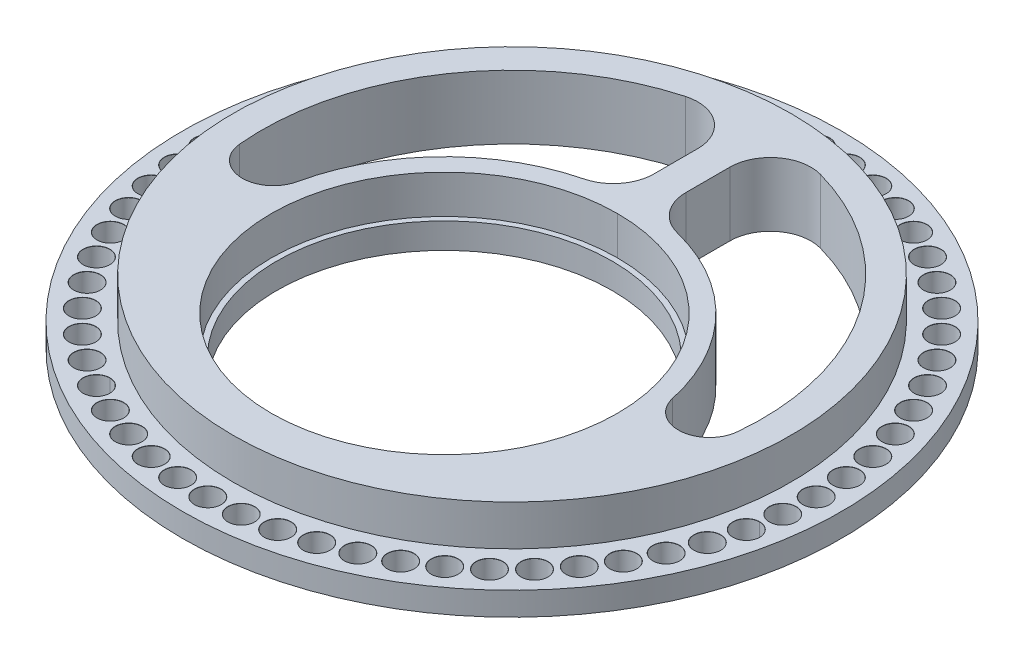
from build123d import *

# Parameters (mm, degrees)
SKETCH1_R                       = 61.9125
SKETCH1_R_2                     = 30.988
SLOTTED_BODY_EXTRUDE_DEPTH      = 4.191
SLOTTED_BODY_EXTRUDE_DEPTH_BACK = 0.2032
SKETCH5_R                       = 52.3875
BOSS_EXTRUDE3_DEPTH             = 7.62
SKETCH6_R                       = 32.512
CUT_EXTRUDE5_DEPTH              = 13.0142
SKETCH8_R                       = 32.512
SKETCH8_R_2                     = 31.496
BOSS_EXTRUDE4_DEPTH             = 4.795000062
CIRPATTERN1_COUNT               = 60


with BuildPart() as part:
    # Sketch1 → Slotted-Body Extrude (new body, two sides)
    with BuildSketch(Plane(origin=(0, 0, 0), x_dir=(1, 0, 0), z_dir=(0, 1, 0))) as slotted_body_extrude_sk:
        Circle(SKETCH1_R)
        with Locations((0, -12.7)):
            Circle(SKETCH1_R_2, mode=Mode.SUBTRACT)
    extrude(amount=SLOTTED_BODY_EXTRUDE_DEPTH)
    extrude(slotted_body_extrude_sk.sketch, amount=-SLOTTED_BODY_EXTRUDE_DEPTH_BACK)

    # Sketch5 → Boss-Extrude3 (add)
    with BuildSketch(Plane(origin=(0, 4.191, 0), x_dir=(1, 0, 0), z_dir=(0, 1, 0))):
        Circle(SKETCH5_R)
    extrude(amount=BOSS_EXTRUDE3_DEPTH)

    # Sketch6 → Cut-Extrude5 (cut, through all)
    with BuildSketch(Plane.XZ.offset(0.2032)):
        with Locations((0, 12.7)):
            Circle(SKETCH6_R)
        with BuildLine():
            Line((3.013951015, -37.906674687), (3.013951015, -29.674053734))
            ThreePointArc((3.013951015, -29.674053734), (4.62572071, -24.987309811), (8.779192117, -22.283230408))
            ThreePointArc((8.779192117, -22.283230408), (25.925135322, -12.375645206), (35.256203169, 5.09074497))
            ThreePointArc((35.256203169, 5.09074497), (41.313127715, 9.689980346), (46.782976949, 4.406037654))
            ThreePointArc((46.782976949, 4.406037654), (38.737451576, -26.59830719), (12.692135082, -45.243450433))
            ThreePointArc((12.692135082, -45.243450433), (6.03063496, -43.979061474), (3.013951015, -37.906674687))
        make_face()
        with BuildLine():
            Line((-3.013951015, -37.906674687), (-3.013951015, -29.674053734))
            ThreePointArc((-3.013951015, -29.674053734), (-4.62572071, -24.987309811), (-8.779192117, -22.283230408))
            ThreePointArc((-8.779192117, -22.283230408), (-25.925135322, -12.375645206), (-35.256203169, 5.09074497))
            ThreePointArc((-35.256203169, 5.09074497), (-41.313127715, 9.689980346), (-46.782976949, 4.406037654))
            ThreePointArc((-46.782976949, 4.406037654), (-38.737451576, -26.59830719), (-12.692135082, -45.243450433))
            ThreePointArc((-12.692135082, -45.243450433), (-6.03063496, -43.979061474), (-3.013951015, -37.906674687))
        make_face()
    extrude(amount=-CUT_EXTRUDE5_DEPTH, mode=Mode.SUBTRACT)

    # Sketch10 → Ø5.0mm Dowel Hole2 (revolve, cut)
    with BuildSketch(Plane(origin=(0, 4.191, -57.15), x_dir=(0, 0, 1), z_dir=(1, 0, 0))):
        Polygon((0, 0), (0, 4.3942), (2.5, 4.3942), (2.5, 0.025), (2.525, 0), align=None)
    f_5_0mm_dowel_hole2 = revolve(axis=Axis((0, 10.541, -57.15), (0, -1, 0)), mode=Mode.SUBTRACT)

    # CirPattern1: Ø5.0mm Dowel Hole2 ×60 about axis
    cirpattern1_axis = Axis((0, 0, 0), (0, 1, 0))
    for i in range(1, CIRPATTERN1_COUNT):
        add(f_5_0mm_dowel_hole2.rotate(cirpattern1_axis, i * 360 / CIRPATTERN1_COUNT), mode=Mode.SUBTRACT)


with BuildPart() as body_2:
    # Sketch8 → Boss-Extrude4 (new body)
    with BuildSketch(Plane.XZ.offset(0.2032)):
        with Locations((0, 12.7)):
            Circle(SKETCH8_R)
        with Locations((0, 12.7)):
            Circle(SKETCH8_R_2, mode=Mode.SUBTRACT)
    extrude(amount=-BOSS_EXTRUDE4_DEPTH)


solid = Compound([part.part, body_2.part])
